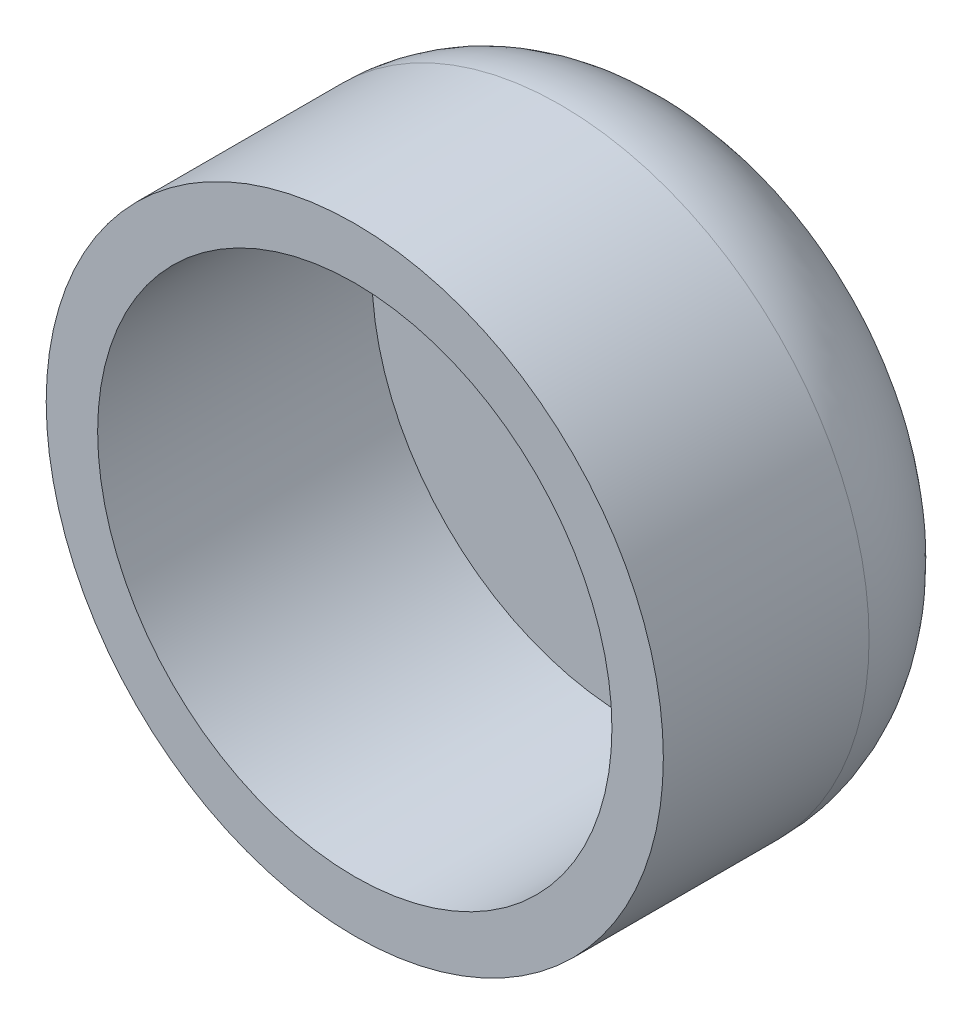
from build123d import *

# Parameters (mm, degrees)
SKETCH1_R           = 0.9
BOSS_EXTRUDE1_DEPTH = 0.5
FILLET1_R           = 0.4
SKETCH2_R           = 0.75
CUT_EXTRUDE1_DEPTH  = 0.3
SKETCH3_R           = 0.9
SKETCH3_R_2         = 0.75
BOSS_EXTRUDE3_DEPTH = 0.5


with BuildPart() as part:
    # Sketch1 → Boss-Extrude1 (new body)
    with BuildSketch(Plane.XY):
        Circle(SKETCH1_R)
    extrude(amount=-BOSS_EXTRUDE1_DEPTH)

    # Fillet1
    fillet1_edges = [part.edges().sort_by_distance(p)[0] for p in [
        (-0.9, 0, -0.5),
    ]]
    fillet(fillet1_edges, radius=FILLET1_R)

    # Sketch2 → Cut-Extrude1 (cut)
    with BuildSketch(Plane.XY):
        Circle(SKETCH2_R)
    extrude(amount=-CUT_EXTRUDE1_DEPTH, mode=Mode.SUBTRACT)

    # Sketch3 → Boss-Extrude3 (add)
    with BuildSketch(Plane.XY):
        Circle(SKETCH3_R)
        Circle(SKETCH3_R_2, mode=Mode.SUBTRACT)
    extrude(amount=BOSS_EXTRUDE3_DEPTH)


solid = part.part
